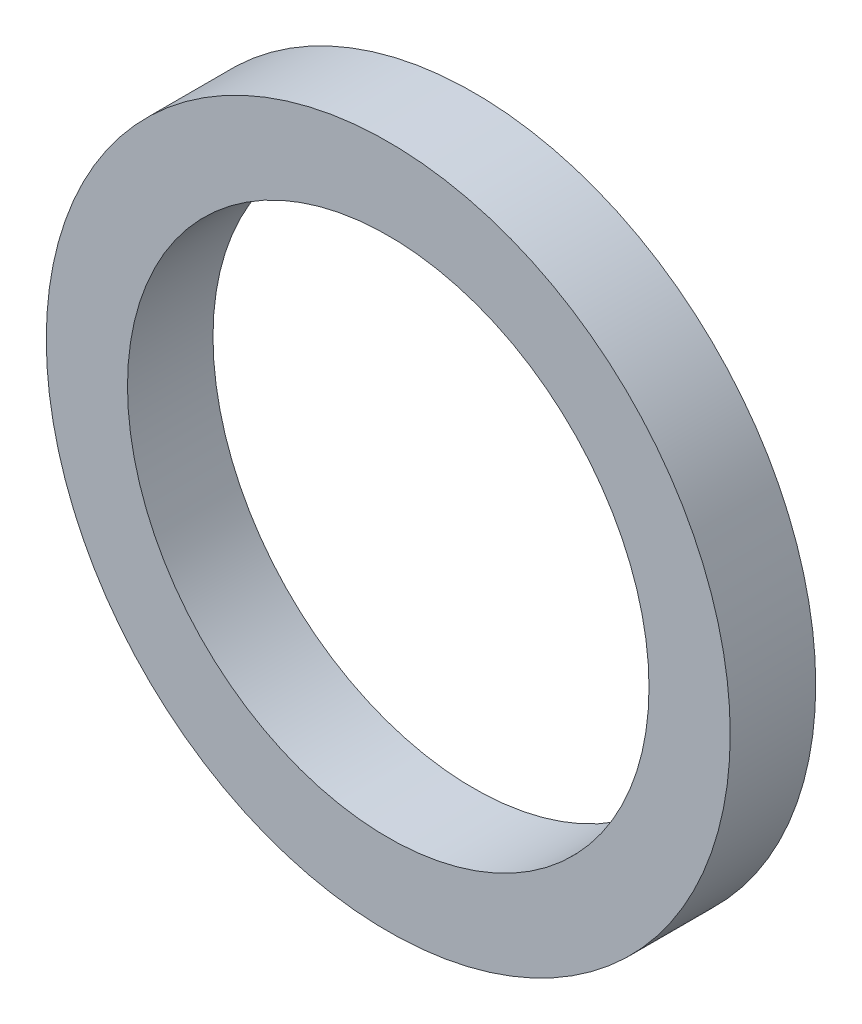
from build123d import *

# Parameters (mm, degrees)
SKIZZE2_R                       = 4
SKIZZE2_R_2                     = 3.05
AUFSATZ_LINEAR_AUSTRAGEN1_DEPTH = 1


with BuildPart() as part:
    # Skizze2 → Aufsatz-Linear austragen1 (new body)
    with BuildSketch(Plane.XY):
        Circle(SKIZZE2_R)
        Circle(SKIZZE2_R_2, mode=Mode.SUBTRACT)
    extrude(amount=-AUFSATZ_LINEAR_AUSTRAGEN1_DEPTH)


solid = part.part
